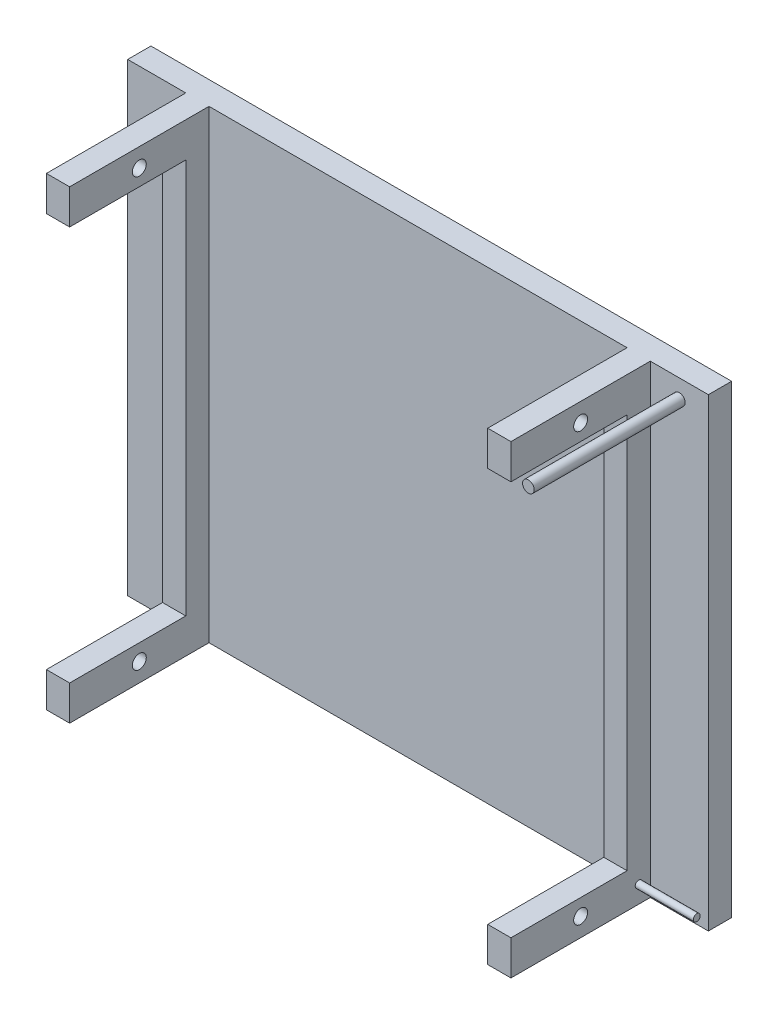
from build123d import *

# Parameters (mm, degrees)
ESQUISSE1_W             = 250
ESQUISSE1_H             = 200
BOSS_EXTRU_1_DEPTH      = 10
ESQUISSE2_W             = 10
ESQUISSE2_H             = 200
BOSS_EXTRU_2_DEPTH      = 60
ESQUISSE3_R             = 3
ESQUISSE3_W             = 50
ESQUISSE3_H             = 170
ENL_V_MAT_EXTRU_1_DEPTH = 226
ESQUISSE4_R             = 2.5
BOSS_EXTRU_5_DEPTH      = 65
ESQUISSE8_R             = 1.5
BOSS_EXTRU_8_DEPTH      = 25


with BuildPart() as part:
    # Esquisse1 → Boss.-Extru.1 (new body)
    with BuildSketch(Plane.XY):
        with Locations((125, -100)):
            Rectangle(ESQUISSE1_W, ESQUISSE1_H)
    extrude(amount=BOSS_EXTRU_1_DEPTH)

    # Esquisse2 → Boss.-Extru.2 (add)
    with BuildSketch(Plane.XY.offset(10)):
        with Locations((30, -100)):
            Rectangle(ESQUISSE2_W, ESQUISSE2_H)
        with Locations((220, -100)):
            Rectangle(ESQUISSE2_W, ESQUISSE2_H)
    extrude(amount=BOSS_EXTRU_2_DEPTH)

    # Esquisse3 → Enlèv. mat.-Extru.1 (cut, through all)
    with BuildSketch(Plane(origin=(225, 0, 0), x_dir=(0, 0, -1), z_dir=(1, 0, 0))):
        with Locations((-40, -192)):
            Circle(ESQUISSE3_R)
        with Locations((-40, -8)):
            Circle(ESQUISSE3_R)
        with Locations((-45, -100)):
            Rectangle(ESQUISSE3_W, ESQUISSE3_H)
    extrude(amount=-ENL_V_MAT_EXTRU_1_DEPTH, mode=Mode.SUBTRACT)

    # Esquisse4 → Boss.-Extru.5 (add)
    with BuildSketch(Plane.XY.offset(10)):
        with Locations((237.5, -8)):
            Circle(ESQUISSE4_R)
    extrude(amount=BOSS_EXTRU_5_DEPTH)

    # Esquisse8 → Boss.-Extru.8 (add)
    with BuildSketch(Plane(origin=(225, 0, 0), x_dir=(0, 0, -1), z_dir=(1, 0, 0))):
        with Locations((-15, -192.5)):
            Circle(ESQUISSE8_R)
    extrude(amount=BOSS_EXTRU_8_DEPTH)


solid = part.part
